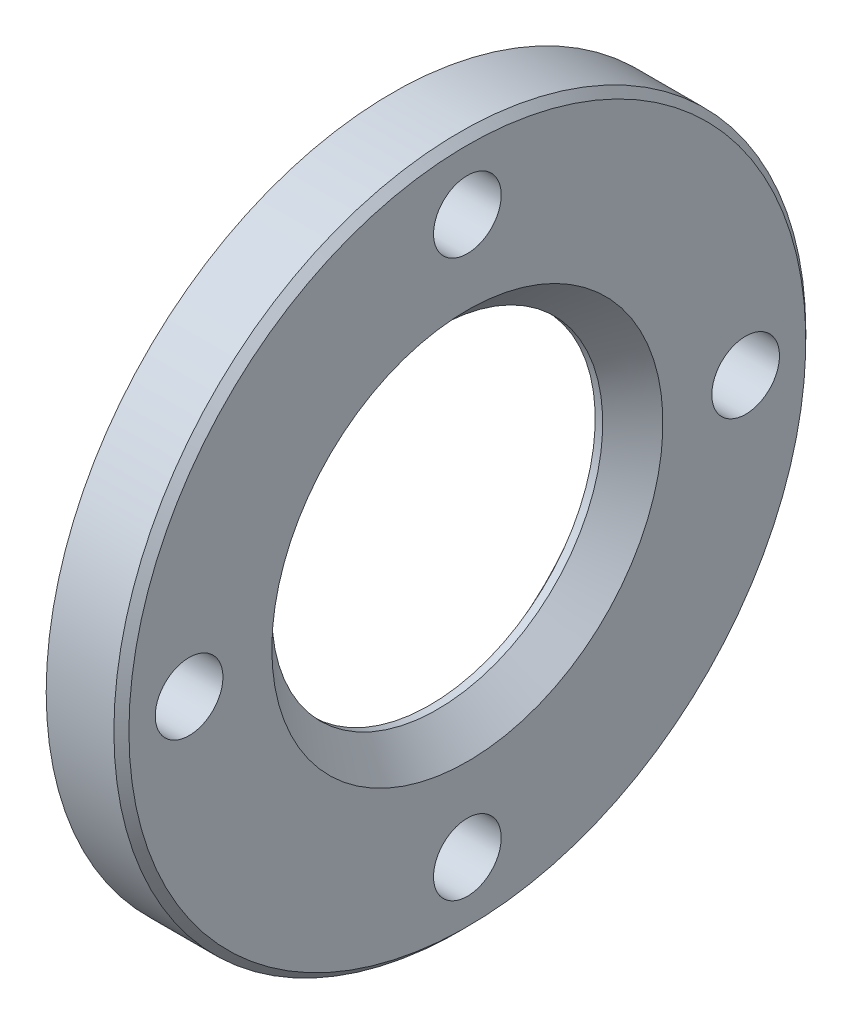
from build123d import *

# Parameters (mm, degrees)
SKETCH_2_R               = 2.25
CUT_EXTRUDE_1_DEPTH      = 33.908965344
PATTERN_CIRCULAR_1_COUNT = 4
CHAMFER_1_SIZE           = 0.5


with BuildPart() as part:
    # Эскиз1 → Повернуть1 (revolve)
    with BuildSketch(Plane.XY, mode=Mode.PRIVATE) as revolve_1_sk:
        Polygon((0, 23), (0, 14.5), (2.5, 14.5), (2.5, 11), (3, 11), (5, 13), (5, 23), align=None)
    revolve(revolve_1_sk.sketch.rotate(Axis((0, 0, 0), (1, 0, 0)), 90), axis=Axis((0, 0, 0), (1, 0, 0)))

    # Эскиз2 → Вырез-Вытянуть1 (cut, through all)
    with BuildSketch(Plane(origin=(5, 0, 0), x_dir=(0, 0, -1), z_dir=(1, 0, 0))):
        with Locations((0, 18.5)):
            Circle(SKETCH_2_R)
    cut_extrude_1 = extrude(amount=-CUT_EXTRUDE_1_DEPTH, mode=Mode.SUBTRACT)

    # Круговой массив1: Вырез-Вытянуть1 ×4 about axis
    pattern_circular_1_axis = Axis((0, 0, 0), (1, 0, 0))
    for i in range(1, PATTERN_CIRCULAR_1_COUNT):
        add(cut_extrude_1.rotate(pattern_circular_1_axis, i * 360 / PATTERN_CIRCULAR_1_COUNT), mode=Mode.SUBTRACT)

    # Фаска1
    chamfer_1_edges = [part.edges().sort_by_distance(p)[0] for p in [
        (5, 0, -23),
    ]]
    chamfer(chamfer_1_edges, length=CHAMFER_1_SIZE)


solid = part.part
